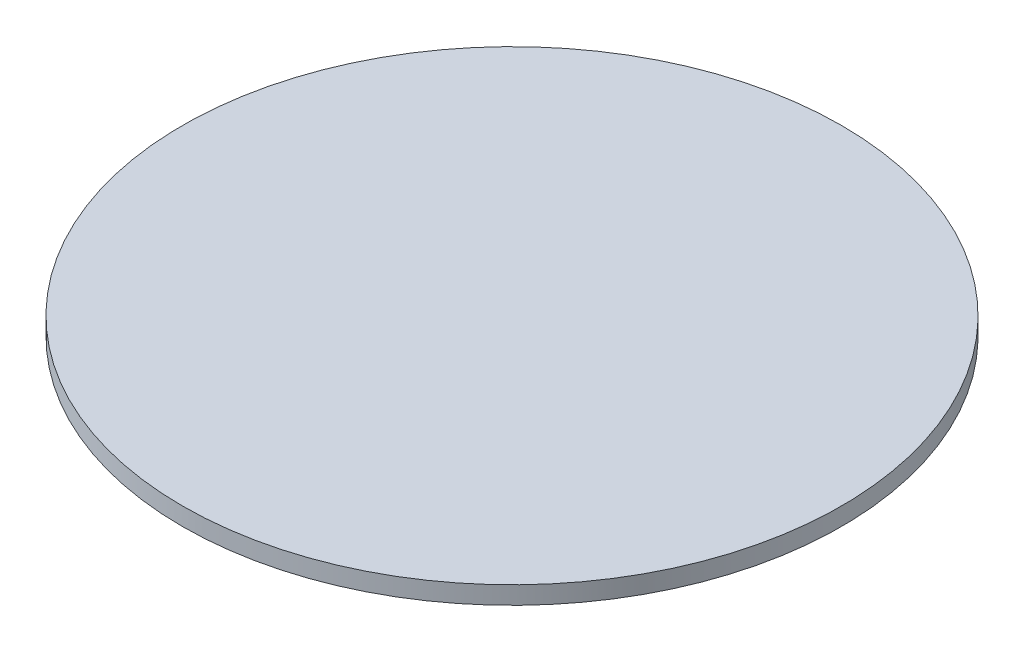
from build123d import *

# Parameters (mm, degrees)
SKETCH_1_R      = 18.5
EXTRUDE_1_DEPTH = 1


with BuildPart() as part:
    # 草图1 → 凸台-拉伸1 (new body)
    with BuildSketch(Plane(origin=(0, 0, 0), x_dir=(1, 0, 0), z_dir=(0, 1, 0))):
        Circle(SKETCH_1_R)
    extrude(amount=EXTRUDE_1_DEPTH)


solid = part.part
